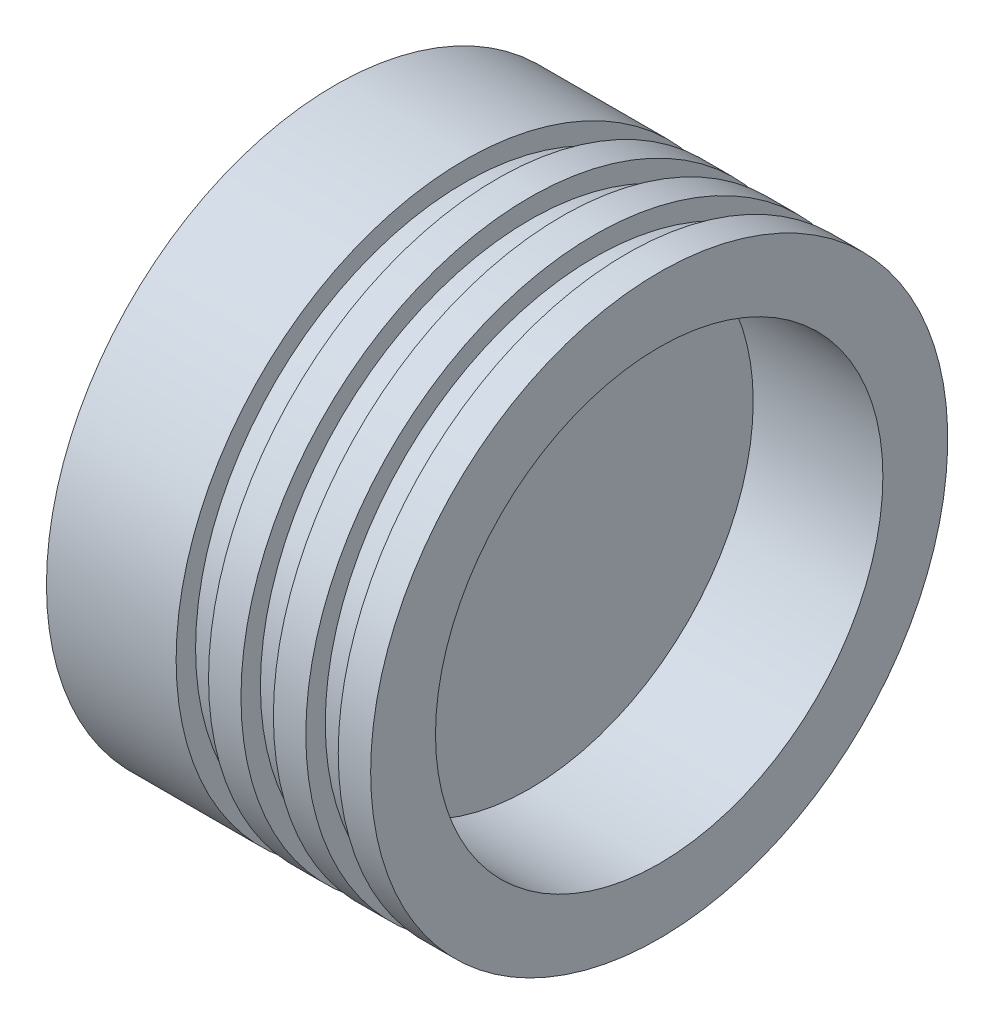
from build123d import *


with BuildPart() as part:
    # Sketch1 → Revolve1 (revolve)
    with BuildSketch(Plane.XY):
        Polygon((0, 0), (0, 44.5), (20, 44.5), (20, 41.5), (25, 41.5), (25, 44.5), (30, 44.5), (30, 41.5), (35, 41.5), (35, 44.5), (40, 44.5), (40, 41.5), (45, 41.5), (45, 44.5), (50, 44.5), (50, 34.5), (30, 34.5), (30, 0), align=None)
    revolve(axis=Axis((0, 0, 0), (1, 0, 0)))


solid = part.part
